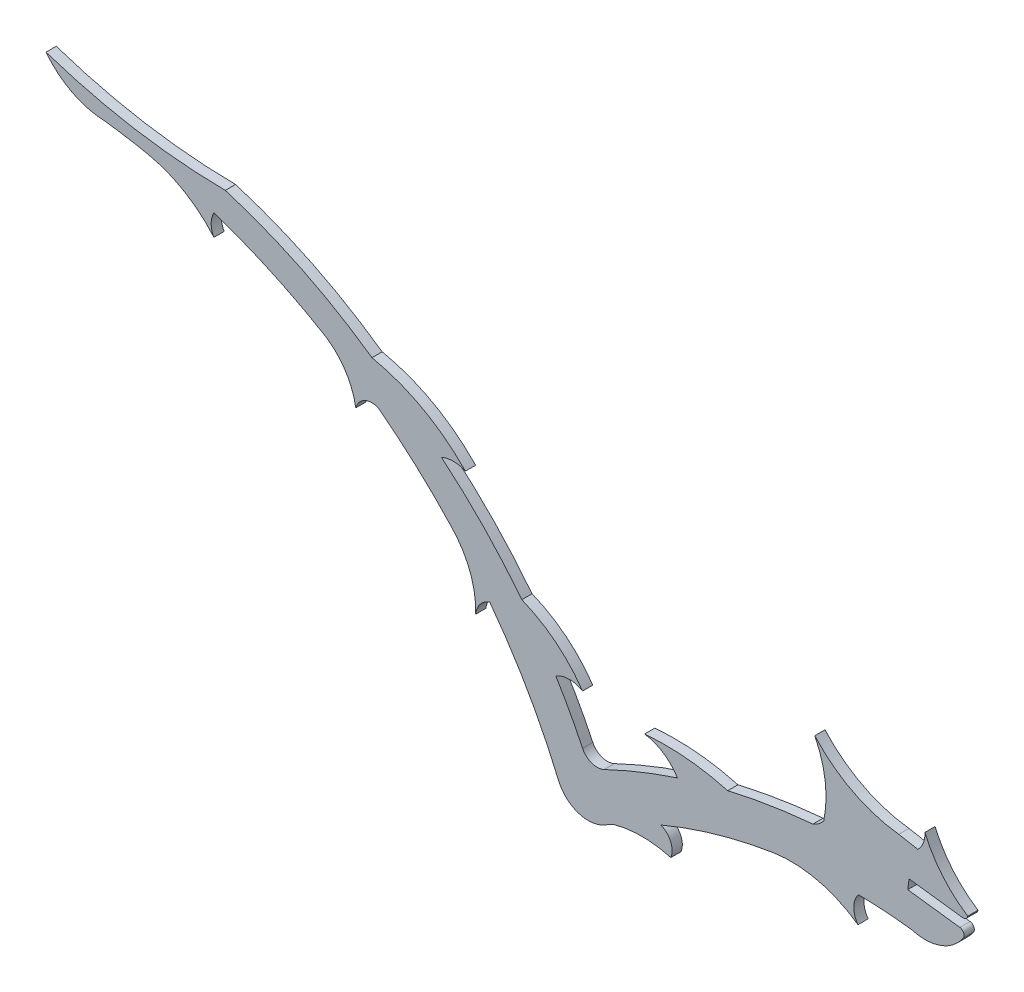
from build123d import *

# Parameters (mm, degrees)
BOSS_EXTRUDE1_DEPTH = 1.524


with BuildPart() as part:
    # Sketch1 → Boss-Extrude1 (new body)
    with BuildSketch(Plane.XY):
        with BuildLine():
            Line((66.817686168, -14.869164569), (59.056150877, -13.876858964))
            Line((59.056150877, -13.876858964), (59.247042617, -12.382986483))
            Line((59.247042617, -12.382986483), (67.194822679, -13.398359477))
            ThreePointArc((67.194822679, -13.398359477), (67.70899541, -13.26788211), (67.995751093, -12.821598434))
            ThreePointArc((67.995751093, -12.821598434), (64.227291304, -9.497799736), (61.607555958, -5.209919876))
            ThreePointArc((61.607555958, -5.209919876), (61.375328576, -6.683073901), (60.554429435, -7.928159013))
            Line((60.554429435, -7.928159013), (57.70805725, -7.403828432))
            ThreePointArc((57.70805725, -7.403828432), (50.857364323, -5.31551987), (45.193330731, -0.93239887))
            ThreePointArc((45.193330731, -0.93239887), (46.74856309, -5.980463476), (46.532138914, -11.258234267))
            ThreePointArc((46.532138914, -11.258234267), (45.814421681, -11.988335606), (44.917143983, -12.481345467))
            ThreePointArc((44.917143983, -12.481345467), (38.532037538, -13.275274102), (32.219333695, -14.520134408))
            ThreePointArc((32.219333695, -14.520134408), (26.075931145, -13.405705196), (19.832270887, -13.398359477))
            ThreePointArc((19.832270887, -13.398359477), (22.636275156, -14.465946733), (24.725407976, -16.619480236))
            ThreePointArc((24.725407976, -16.619480236), (19.193818209, -18.629561925), (13.804325827, -20.994363314))
            ThreePointArc((13.804325827, -20.994363314), (11.961969019, -21.092468706), (10.589989147, -19.858947525))
            ThreePointArc((10.589989147, -19.858947525), (8.692873036, -16.140740523), (6.604648633, -12.52640356))
            ThreePointArc((6.604648633, -12.52640356), (8.591060293, -11.950308262), (10.589989147, -12.481345467))
            ThreePointArc((10.589989147, -12.481345467), (6.604648633, -8.173624539), (1.539487899, -5.209919876))
            ThreePointArc((1.539487899, -5.209919876), (-4.115983201, 1.303955497), (-10.439102907, 7.171926434))
            ThreePointArc((-10.439102907, 7.171926434), (-8.653197321, 7.552707081), (-6.867291735, 7.171926434))
            ThreePointArc((-6.867291735, 7.171926434), (-13.248231641, 12.071035928), (-20.796462113, 14.853460169))
            ThreePointArc((-20.796462113, 14.853460169), (-31.29237864, 21.067135925), (-42.647396117, 25.521078925))
            ThreePointArc((-42.647396117, 25.521078925), (-56.186845853, 26.702409902), (-69.371487811, 30.000509128))
            ThreePointArc((-69.371487811, 30.000509128), (-65.415318989, 26.726735017), (-60.436877471, 25.468168876))
            ThreePointArc((-60.436877471, 25.468168876), (-57.284615578, 25.003207948), (-54.152019191, 24.420298363))
            ThreePointArc((-54.152019191, 24.420298363), (-48.766215804, 22.329910268), (-44.346090572, 18.609817064))
            ThreePointArc((-44.346090572, 18.609817064), (-44.75848849, 20.197264615), (-44.346090572, 21.784712166))
            ThreePointArc((-44.346090572, 21.784712166), (-35.698486655, 18.358779729), (-27.477516693, 14.007490327))
            ThreePointArc((-27.477516693, 14.007490327), (-24.652349792, 11.020731115), (-23.207012071, 7.171926434))
            ThreePointArc((-23.207012071, 7.171926434), (-21.929330632, 8.763840822), (-19.890640696, 8.865843888))
            ThreePointArc((-19.890640696, 8.865843888), (-14.26749676, 4.199817582), (-9.066352318, -0.93239887))
            ThreePointArc((-9.066352318, -0.93239887), (-6.212207546, -5.345518339), (-5.336411329, -10.527674919))
            ThreePointArc((-5.336411329, -10.527674919), (-4.676038807, -8.910060646), (-3.250173943, -7.900269978))
            ThreePointArc((-3.250173943, -7.900269978), (2.428109507, -16.545845472), (7.012996253, -25.817721879))
            ThreePointArc((7.012996253, -25.817721879), (9.928518411, -28.520179408), (13.883000235, -28.113215463))
            ThreePointArc((13.883000235, -28.113215463), (14.506734037, -27.753899557), (15.133981782, -27.400753634))
            ThreePointArc((15.133981782, -27.400753634), (19.438401061, -26.804711741), (23.74282034, -27.400753634))
            ThreePointArc((23.74282034, -27.400753634), (23.721132898, -25.36083225), (22.275997143, -23.920925222))
            ThreePointArc((22.275997143, -23.920925222), (30.525936774, -21.012373591), (39.064631831, -19.111883331))
            ThreePointArc((39.064631831, -19.111883331), (45.641469135, -19.389960489), (51.636059466, -22.1097036))
            ThreePointArc((51.636059466, -22.1097036), (51.007316283, -20.144641068), (51.693543332, -18.19890697))
            ThreePointArc((51.693543332, -18.19890697), (55.664100075, -18.365490547), (59.619700642, -18.74797596))
            ThreePointArc((59.619700642, -18.74797596), (63.927856855, -18.638412611), (67.326700796, -15.988870395))
            ThreePointArc((67.326700796, -15.988870395), (67.384238378, -15.287162887), (66.817686168, -14.869164569))
        make_face()
    extrude(amount=BOSS_EXTRUDE1_DEPTH)


solid = part.part
